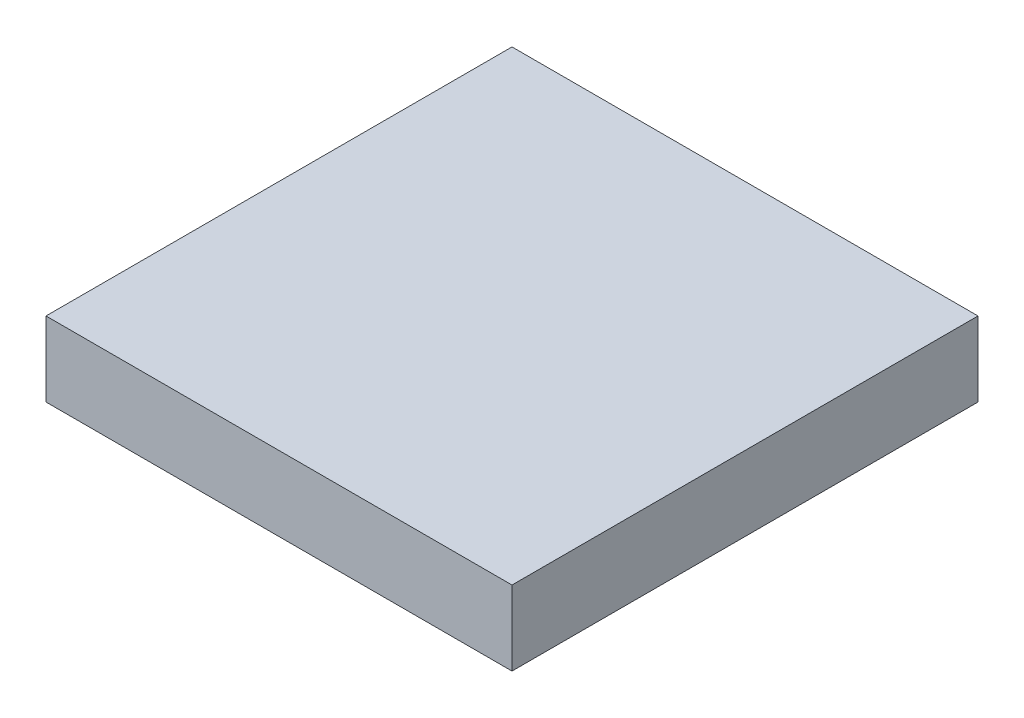
from build123d import *

# Parameters (mm, degrees)
SKETCH1_W           = 19.05
SKETCH1_H           = 19.05
BOSS_EXTRUDE1_DEPTH = 3.048


with BuildPart() as part:
    # Sketch1 → Boss-Extrude1 (new body)
    with BuildSketch(Plane(origin=(0, 0, 0), x_dir=(1, 0, 0), z_dir=(0, 1, 0))):
        Rectangle(SKETCH1_W, SKETCH1_H)
    extrude(amount=BOSS_EXTRUDE1_DEPTH)


solid = part.part
